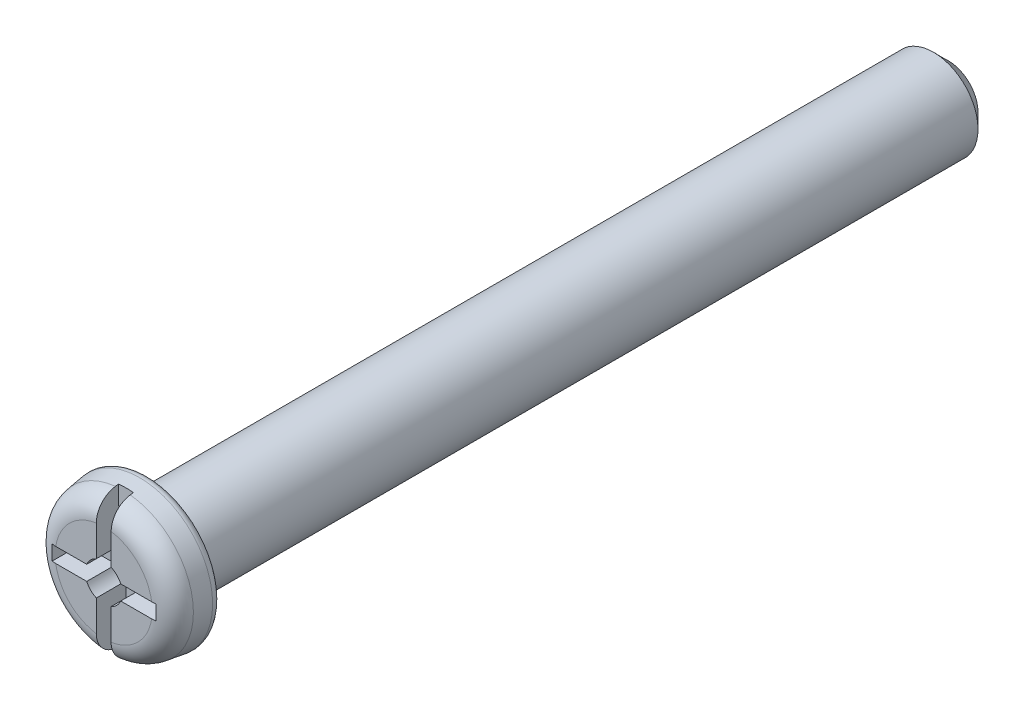
from build123d import *

# Parameters (mm, degrees)
ESQUISSE1_R             = 2.5
BASE_EXTRUSION_DEPTH    = 1.5
BASE_EXTRUSION_TAPER    = 8
CONG_1_R                = 0.75
CONG_2_R                = 0.25
ESQUISSE2_R             = 1.5
BOSS_EXTRU_1_DEPTH      = 27
CHANFREIN1_SIZE         = 0.5
ENL_V_MAT_EXTRU_1_DEPTH = 1
ESQUISSE5_W             = 0.5
ESQUISSE5_H             = 5.000243794
ENL_V_MAT_EXTRU_2_DEPTH = 0.75


with BuildPart() as part:
    # Esquisse1 → Base-Extrusion (new body)
    with BuildSketch(Plane.XY):
        Circle(ESQUISSE1_R)
    extrude(amount=BASE_EXTRUSION_DEPTH, taper=BASE_EXTRUSION_TAPER)

    # Congé1
    cong_1_edges = [part.edges().sort_by_distance(p)[0] for p in [
        (-2.289188748, 0, 1.5),
    ]]
    fillet(cong_1_edges, radius=CONG_1_R)

    # Congé2
    cong_2_edges = [part.edges().sort_by_distance(p)[0] for p in [
        (-2.5, 0, 0),
    ]]
    fillet(cong_2_edges, radius=CONG_2_R)

    # Esquisse2 → Boss.-Extru.1 (add)
    with BuildSketch(Plane(origin=(0, 0, 0), x_dir=(-1, 0, 0), z_dir=(0, 0, -1))):
        Circle(ESQUISSE2_R)
    extrude(amount=BOSS_EXTRU_1_DEPTH)

    # Chanfrein1
    chanfrein1_edges = [part.edges().sort_by_distance(p)[0] for p in [
        (1.5, 0, -27),
    ]]
    chamfer(chanfrein1_edges, length=CHANFREIN1_SIZE)

    # Esquisse4 → Enlèv. mat.-Extru.1 (cut)
    with BuildSketch(Plane.XY.offset(1.5)):
        with BuildLine():
            Line((-0.25, 1.75), (-0.25, 0.572821962))
            ThreePointArc((-0.25, 0.572821962), (-0.441941738, 0.441941738), (-0.572821962, 0.25))
            Line((-0.572821962, 0.25), (-1.75, 0.25))
            Line((-1.75, 0.25), (-1.75, -0.25))
            Line((-1.75, -0.25), (-0.572821962, -0.25))
            ThreePointArc((-0.572821962, -0.25), (-0.441941738, -0.441941738), (-0.25, -0.572821962))
            Line((-0.25, -0.572821962), (-0.25, -1.75))
            Line((-0.25, -1.75), (0.25, -1.75))
            Line((0.25, -1.75), (0.25, -0.572821962))
            ThreePointArc((0.25, -0.572821962), (0.441941738, -0.441941738), (0.572821962, -0.25))
            Line((0.572821962, -0.25), (1.75, -0.25))
            Line((1.75, -0.25), (1.75, 0.25))
            Line((1.75, 0.25), (0.572821962, 0.25))
            ThreePointArc((0.572821962, 0.25), (0.441941738, 0.441941738), (0.25, 0.572821962))
            Line((0.25, 0.572821962), (0.25, 1.75))
            Line((0.25, 1.75), (-0.25, 1.75))
        make_face()
    extrude(amount=-ENL_V_MAT_EXTRU_1_DEPTH, mode=Mode.SUBTRACT)

    # Esquisse5 → Enlèv. mat.-Extru.2 (cut)
    with BuildSketch(Plane.XY.offset(1.5)):
        with Locations((0, 0.01124212)):
            Rectangle(ESQUISSE5_W, ESQUISSE5_H)
    extrude(amount=-ENL_V_MAT_EXTRU_2_DEPTH, mode=Mode.SUBTRACT)


solid = part.part
